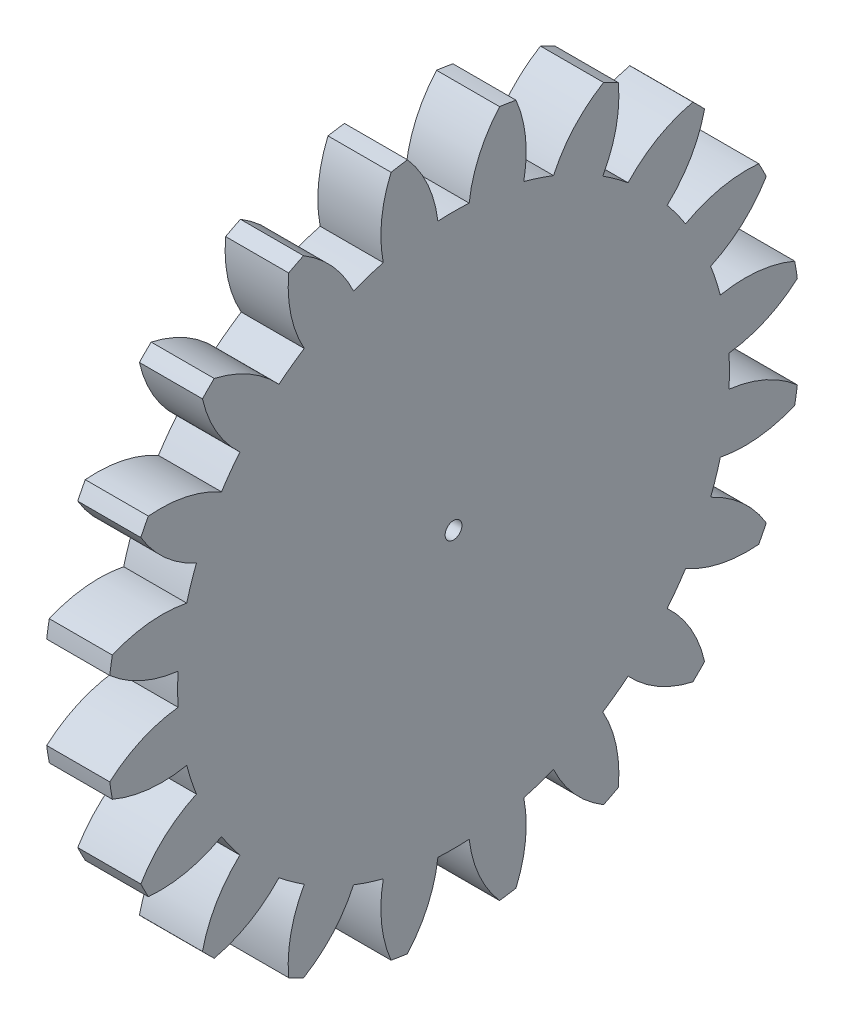
from build123d import *

# Parameters (mm, degrees)
BASPROSKE_W     = 3
BASPROSKE_H     = 16.5
TOOTHCUT_DEPTH  = 24.526580712
TEETHCUTS_COUNT = 20
TEETHCUTS_ANGLE = 342
BORSKE_R        = 0.4
BORE_DEPTH      = 50.0000508


with BuildPart() as part:
    # BasProSke → Base-Revolve (revolve)
    with BuildSketch(Plane(origin=(0, 0, 0), x_dir=(1, 0, 0), z_dir=(0, 1, 0)), mode=Mode.PRIVATE) as base_revolve_sk:
        with Locations((1.5, 8.25)):
            Rectangle(BASPROSKE_W, BASPROSKE_H)
    revolve(base_revolve_sk.sketch.rotate(Axis((-10, 0, 0), (1, 0, 0)), 180), axis=Axis((-10, 0, 0), (1, 0, 0)))

    # TooCutSke → ToothCut (cut, through all)
    with BuildSketch(Plane(origin=(0, 0, 0), x_dir=(0, 0, -1), z_dir=(1, 0, 0))):
        with BuildLine():
            ThreePointArc((0.74381438, 13.102904875), (0, 13.124), (-0.74381438, 13.102904875))
            ThreePointArc((-0.74381438, 13.102904875), (-1.226473103, 14.852072512), (-2.209965745, 16.376962373))
            ThreePointArc((-2.209965745, 16.376962373), (0, 16.5254), (2.209965745, 16.376962373))
            ThreePointArc((2.209965745, 16.376962373), (1.226473103, 14.852072512), (0.74381438, 13.102904875))
        make_face()
    toothcut = extrude(amount=TOOTHCUT_DEPTH, mode=Mode.SUBTRACT)

    # TeethCuts: ToothCut ×20 about axis
    teethcuts_axis = Axis((-10, 0, 0), (1, 0, 0))
    for i in range(1, TEETHCUTS_COUNT):
        add(toothcut.rotate(teethcuts_axis, i * TEETHCUTS_ANGLE / (TEETHCUTS_COUNT - 1)), mode=Mode.SUBTRACT)

    # BorSke → Bore (cut, symmetric)
    with BuildSketch(Plane(origin=(0, 0, 0), x_dir=(0, 0, -1), z_dir=(1, 0, 0))):
        with Locations(Location((0, 0, 0), (0, 0, 180))):
            Circle(BORSKE_R)
    extrude(amount=BORE_DEPTH, both=True, mode=Mode.SUBTRACT)


solid = part.part
